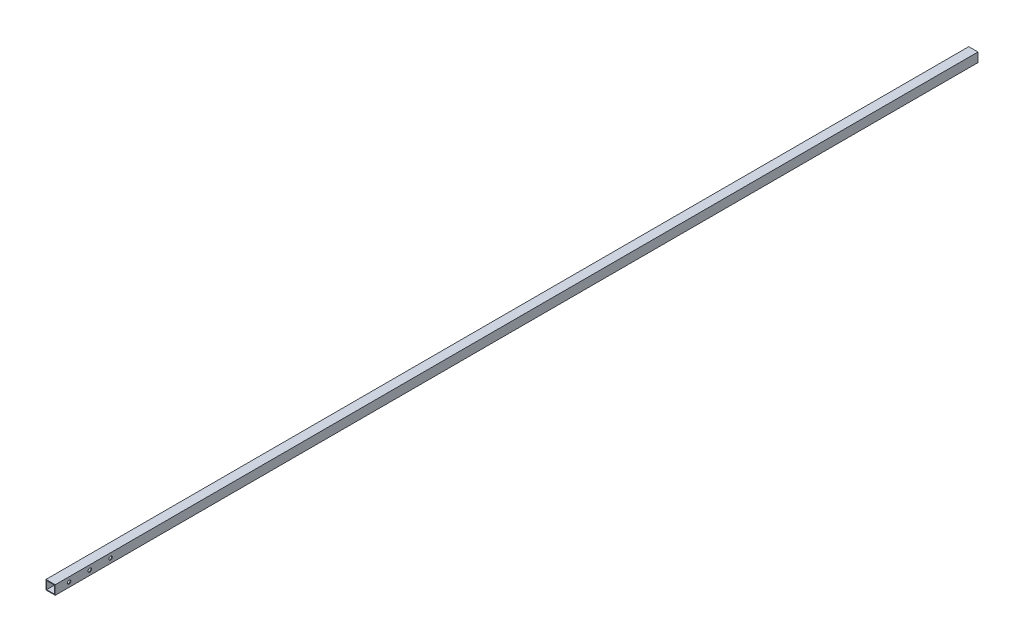
from build123d import *

# Parameters (mm, degrees)
CROQUIS1_W              = 40
CROQUIS1_H              = 40
CROQUIS1_W_2            = 34
CROQUIS1_H_2            = 34
SALIENTE_EXTRUIR1_DEPTH = 4000
CROQUIS2_R              = 7.5
CORTAR_EXTRUIR1_DEPTH   = 40


with BuildPart() as part:
    # Croquis1 → Saliente-Extruir1 (new body)
    with BuildSketch(Plane.XY):
        Rectangle(CROQUIS1_W, CROQUIS1_H)
        Rectangle(CROQUIS1_W_2, CROQUIS1_H_2, mode=Mode.SUBTRACT)
    extrude(amount=SALIENTE_EXTRUIR1_DEPTH)

    # Croquis2 → Cortar-Extruir1 (cut)
    with BuildSketch(Plane(origin=(20, 0, 0), x_dir=(0, 0, -1), z_dir=(1, 0, 0))):
        with BuildLine():
            ThreePointArc((-3932.5, 0), (-3940, 7.5), (-3947.5, 0))
            Line((-3947.5, 0), (-3932.5, 0))
        make_face()
        with BuildLine():
            Line((-3932.5, 0), (-3947.5, 0))
            ThreePointArc((-3947.5, 0), (-3940, -7.5), (-3932.5, 0))
        make_face()
        with BuildLine():
            ThreePointArc((-3842.5, 0), (-3850, 7.5), (-3857.5, 0))
            Line((-3857.5, 0), (-3842.5, 0))
        make_face()
        with BuildLine():
            Line((-3842.5, 0), (-3857.5, 0))
            ThreePointArc((-3857.5, 0), (-3850, -7.5), (-3842.5, 0))
        make_face()
        with Locations((-3760, 0)):
            Circle(CROQUIS2_R)
    extrude(amount=-CORTAR_EXTRUIR1_DEPTH, mode=Mode.SUBTRACT)


solid = part.part
